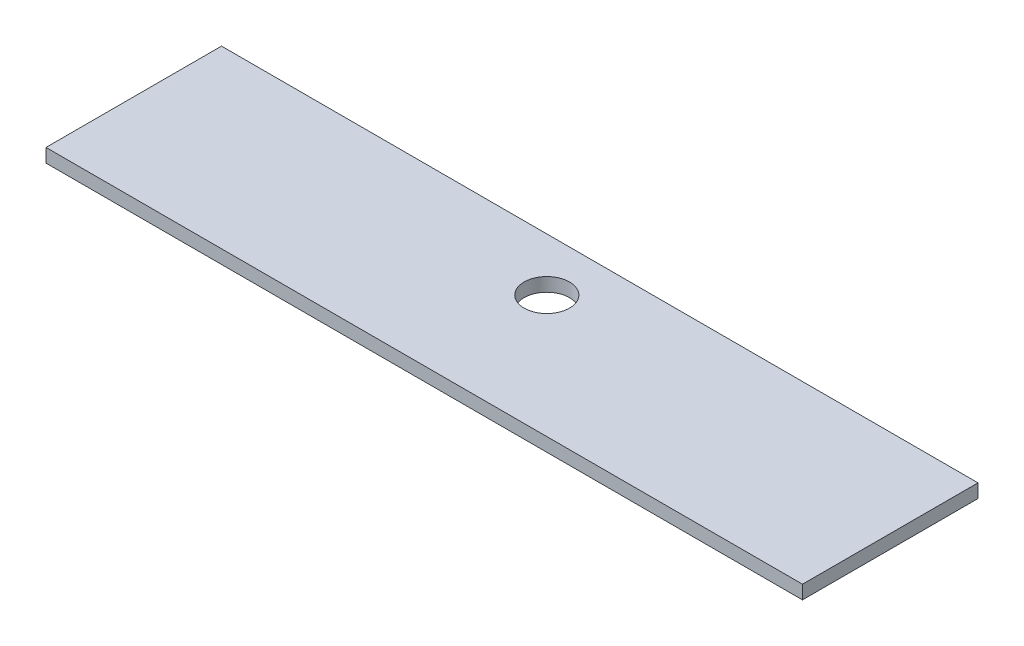
from build123d import *

# Parameters (mm, degrees)
SKETCH1_W           = 1000
SKETCH1_H           = 232
BOSS_EXTRUDE1_DEPTH = 18
SKETCH2_R           = 30
CUT_EXTRUDE1_DEPTH  = 18


with BuildPart() as part:
    # Sketch1 → Boss-Extrude1 (new body)
    with BuildSketch(Plane(origin=(0, 0, 0), x_dir=(1, 0, 0), z_dir=(0, 1, 0))):
        with Locations((416.474412506, -76.882229965)):
            Rectangle(SKETCH1_W, SKETCH1_H)
    extrude(amount=BOSS_EXTRUDE1_DEPTH)

    # Sketch2 → Cut-Extrude1 (cut)
    with BuildSketch(Plane(origin=(0, 18, 0), x_dir=(1, 0, 0), z_dir=(0, 1, 0))):
        with Locations((416.474412506, -30.882229965)):
            Circle(SKETCH2_R)
    extrude(amount=-CUT_EXTRUDE1_DEPTH, mode=Mode.SUBTRACT)


solid = part.part
